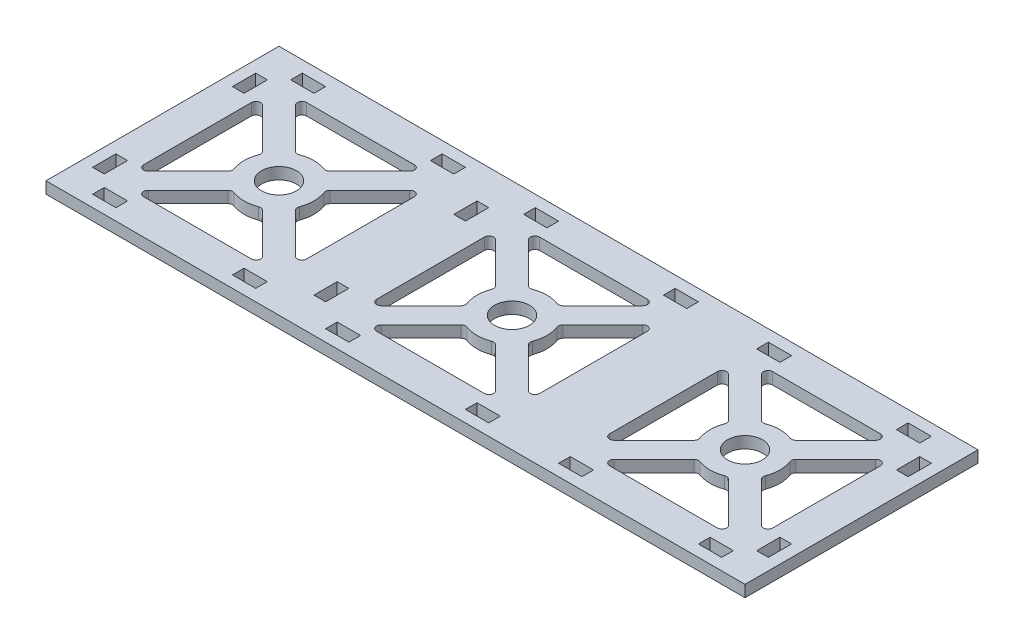
from build123d import *

# Parameters (mm, degrees)
SKETCH1_R           = 7.5
SKETCH1_W           = 10
SKETCH1_H           = 5
SKETCH1_W_2         = 5
SKETCH1_H_2         = 10
BOSS_EXTRUDE2_DEPTH = 5


with BuildPart() as part:
    # Sketch1 → Boss-Extrude2 (new body)
    with BuildSketch(Plane(origin=(0, 0, 0), x_dir=(1, 0, 0), z_dir=(0, 1, 0))):
        Polygon((-50, 50), (150, 50), (150, -50), (-50, -50), (-150, -50), (-150, 50), align=None)
        Circle(SKETCH1_R, mode=Mode.SUBTRACT)
        with Locations((100, 0)):
            Circle(SKETCH1_R, mode=Mode.SUBTRACT)
        with Locations((-100, 0)):
            Circle(SKETCH1_R, mode=Mode.SUBTRACT)
        with BuildLine():
            Line((-23.100505063, 35), (23.100505063, 35))
            ThreePointArc((23.100505063, 35), (24.948264128, 33.765366865), (24.514718626, 31.585786438))
            Line((24.514718626, 31.585786438), (7.418917244, 14.489985056))
            ThreePointArc((7.418917244, 14.489985056), (6.425915745, 13.949056578), (5.298267955, 14.033116428))
            ThreePointArc((5.298267955, 14.033116428), (0, 15), (-5.298267955, 14.033116428))
            ThreePointArc((-5.298267955, 14.033116428), (-6.425915745, 13.949056578), (-7.418917244, 14.489985056))
            Line((-7.418917244, 14.489985056), (-24.514718626, 31.585786438))
            ThreePointArc((-24.514718626, 31.585786438), (-24.948264128, 33.765366865), (-23.100505063, 35))
        make_face(mode=Mode.SUBTRACT)
        with BuildLine():
            Line((-35, 23.100505063), (-35, -23.100505063))
            ThreePointArc((-35, -23.100505063), (-33.765366865, -24.948264128), (-31.585786438, -24.514718626))
            Line((-31.585786438, -24.514718626), (-14.489985056, -7.418917244))
            ThreePointArc((-14.489985056, -7.418917244), (-13.949056578, -6.425915745), (-14.033116428, -5.298267955))
            ThreePointArc((-14.033116428, -5.298267955), (-15, 0), (-14.033116428, 5.298267955))
            ThreePointArc((-14.033116428, 5.298267955), (-13.949056578, 6.425915745), (-14.489985056, 7.418917244))
            Line((-14.489985056, 7.418917244), (-31.585786438, 24.514718626))
            ThreePointArc((-31.585786438, 24.514718626), (-33.765366865, 24.948264128), (-35, 23.100505063))
        make_face(mode=Mode.SUBTRACT)
        with BuildLine():
            Line((-23.100505063, -35), (23.100505063, -35))
            ThreePointArc((23.100505063, -35), (24.948264128, -33.765366865), (24.514718626, -31.585786438))
            Line((24.514718626, -31.585786438), (7.418917244, -14.489985056))
            ThreePointArc((7.418917244, -14.489985056), (6.425915745, -13.949056578), (5.298267955, -14.033116428))
            ThreePointArc((5.298267955, -14.033116428), (0, -15), (-5.298267955, -14.033116428))
            ThreePointArc((-5.298267955, -14.033116428), (-6.425915745, -13.949056578), (-7.418917244, -14.489985056))
            Line((-7.418917244, -14.489985056), (-24.514718626, -31.585786438))
            ThreePointArc((-24.514718626, -31.585786438), (-24.948264128, -33.765366865), (-23.100505063, -35))
        make_face(mode=Mode.SUBTRACT)
        with BuildLine():
            Line((35, 23.100505063), (35, -23.100505063))
            ThreePointArc((35, -23.100505063), (33.765366865, -24.948264128), (31.585786438, -24.514718626))
            Line((31.585786438, -24.514718626), (14.489985056, -7.418917244))
            ThreePointArc((14.489985056, -7.418917244), (13.949056578, -6.425915745), (14.033116428, -5.298267955))
            ThreePointArc((14.033116428, -5.298267955), (15, 0), (14.033116428, 5.298267955))
            ThreePointArc((14.033116428, 5.298267955), (13.949056578, 6.425915745), (14.489985056, 7.418917244))
            Line((14.489985056, 7.418917244), (31.585786438, 24.514718626))
            ThreePointArc((31.585786438, 24.514718626), (33.765366865, 24.948264128), (35, 23.100505063))
        make_face(mode=Mode.SUBTRACT)
        with BuildLine():
            Line((131.585786438, -24.514718626), (114.489985056, -7.418917244))
            ThreePointArc((114.489985056, -7.418917244), (113.949056578, -6.425915745), (114.033116428, -5.298267955))
            ThreePointArc((114.033116428, -5.298267955), (115, 0), (114.033116428, 5.298267955))
            ThreePointArc((114.033116428, 5.298267955), (113.949056578, 6.425915745), (114.489985056, 7.418917244))
            Line((114.489985056, 7.418917244), (131.585786438, 24.514718626))
            ThreePointArc((131.585786438, 24.514718626), (133.765366865, 24.948264128), (135, 23.100505063))
            Line((135, 23.100505063), (135, -23.100505063))
            ThreePointArc((135, -23.100505063), (133.765366865, -24.948264128), (131.585786438, -24.514718626))
        make_face(mode=Mode.SUBTRACT)
        with BuildLine():
            Line((124.514718626, -31.585786438), (107.418917244, -14.489985056))
            ThreePointArc((107.418917244, -14.489985056), (106.425915745, -13.949056578), (105.298267955, -14.033116428))
            ThreePointArc((105.298267955, -14.033116428), (100, -15), (94.701732045, -14.033116428))
            ThreePointArc((94.701732045, -14.033116428), (93.574084255, -13.949056578), (92.581082756, -14.489985056))
            Line((92.581082756, -14.489985056), (75.485281374, -31.585786438))
            ThreePointArc((75.485281374, -31.585786438), (75.051735872, -33.765366865), (76.899494937, -35))
            Line((76.899494937, -35), (123.100505063, -35))
            ThreePointArc((123.100505063, -35), (124.948264128, -33.765366865), (124.514718626, -31.585786438))
        make_face(mode=Mode.SUBTRACT)
        with BuildLine():
            Line((68.414213562, -24.514718626), (85.510014944, -7.418917244))
            ThreePointArc((85.510014944, -7.418917244), (86.050943422, -6.425915745), (85.966883572, -5.298267955))
            ThreePointArc((85.966883572, -5.298267955), (85, 0), (85.966883572, 5.298267955))
            ThreePointArc((85.966883572, 5.298267955), (86.050943422, 6.425915745), (85.510014944, 7.418917244))
            Line((85.510014944, 7.418917244), (68.414213562, 24.514718626))
            ThreePointArc((68.414213562, 24.514718626), (66.234633135, 24.948264128), (65, 23.100505063))
            Line((65, 23.100505063), (65, -23.100505063))
            ThreePointArc((65, -23.100505063), (66.234633135, -24.948264128), (68.414213562, -24.514718626))
        make_face(mode=Mode.SUBTRACT)
        with BuildLine():
            Line((75.485281374, 31.585786438), (92.581082756, 14.489985056))
            ThreePointArc((92.581082756, 14.489985056), (93.574084255, 13.949056578), (94.701732045, 14.033116428))
            ThreePointArc((94.701732045, 14.033116428), (100, 15), (105.298267955, 14.033116428))
            ThreePointArc((105.298267955, 14.033116428), (106.425915745, 13.949056578), (107.418917244, 14.489985056))
            Line((107.418917244, 14.489985056), (124.514718626, 31.585786438))
            ThreePointArc((124.514718626, 31.585786438), (124.948264128, 33.765366865), (123.100505063, 35))
            Line((123.100505063, 35), (76.899494937, 35))
            ThreePointArc((76.899494937, 35), (75.051735872, 33.765366865), (75.485281374, 31.585786438))
        make_face(mode=Mode.SUBTRACT)
        with BuildLine():
            Line((-68.414213562, -24.514718626), (-85.510014944, -7.418917244))
            ThreePointArc((-85.510014944, -7.418917244), (-86.050943422, -6.425915745), (-85.966883572, -5.298267955))
            ThreePointArc((-85.966883572, -5.298267955), (-85, 0), (-85.966883572, 5.298267955))
            ThreePointArc((-85.966883572, 5.298267955), (-86.050943422, 6.425915745), (-85.510014944, 7.418917244))
            Line((-85.510014944, 7.418917244), (-68.414213562, 24.514718626))
            ThreePointArc((-68.414213562, 24.514718626), (-66.234633135, 24.948264128), (-65, 23.100505063))
            Line((-65, 23.100505063), (-65, -23.100505063))
            ThreePointArc((-65, -23.100505063), (-66.234633135, -24.948264128), (-68.414213562, -24.514718626))
        make_face(mode=Mode.SUBTRACT)
        with BuildLine():
            Line((-75.485281374, -31.585786438), (-92.581082756, -14.489985056))
            ThreePointArc((-92.581082756, -14.489985056), (-93.574084255, -13.949056578), (-94.701732045, -14.033116428))
            ThreePointArc((-94.701732045, -14.033116428), (-100, -15), (-105.298267955, -14.033116428))
            ThreePointArc((-105.298267955, -14.033116428), (-106.425915745, -13.949056578), (-107.418917244, -14.489985056))
            Line((-107.418917244, -14.489985056), (-124.514718626, -31.585786438))
            ThreePointArc((-124.514718626, -31.585786438), (-124.948264128, -33.765366865), (-123.100505063, -35))
            Line((-123.100505063, -35), (-76.899494937, -35))
            ThreePointArc((-76.899494937, -35), (-75.051735872, -33.765366865), (-75.485281374, -31.585786438))
        make_face(mode=Mode.SUBTRACT)
        with BuildLine():
            Line((-131.585786438, -24.514718626), (-114.489985056, -7.418917244))
            ThreePointArc((-114.489985056, -7.418917244), (-113.949056578, -6.425915745), (-114.033116428, -5.298267955))
            ThreePointArc((-114.033116428, -5.298267955), (-115, 0), (-114.033116428, 5.298267955))
            ThreePointArc((-114.033116428, 5.298267955), (-113.949056578, 6.425915745), (-114.489985056, 7.418917244))
            Line((-114.489985056, 7.418917244), (-131.585786438, 24.514718626))
            ThreePointArc((-131.585786438, 24.514718626), (-133.765366865, 24.948264128), (-135, 23.100505063))
            Line((-135, 23.100505063), (-135, -23.100505063))
            ThreePointArc((-135, -23.100505063), (-133.765366865, -24.948264128), (-131.585786438, -24.514718626))
        make_face(mode=Mode.SUBTRACT)
        with BuildLine():
            Line((-124.514718626, 31.585786438), (-107.418917244, 14.489985056))
            ThreePointArc((-107.418917244, 14.489985056), (-106.425915745, 13.949056578), (-105.298267955, 14.033116428))
            ThreePointArc((-105.298267955, 14.033116428), (-100, 15), (-94.701732045, 14.033116428))
            ThreePointArc((-94.701732045, 14.033116428), (-93.574084255, 13.949056578), (-92.581082756, 14.489985056))
            Line((-92.581082756, 14.489985056), (-75.485281374, 31.585786438))
            ThreePointArc((-75.485281374, 31.585786438), (-75.051735872, 33.765366865), (-76.899494937, 35))
            Line((-76.899494937, 35), (-123.100505063, 35))
            ThreePointArc((-123.100505063, 35), (-124.948264128, 33.765366865), (-124.514718626, 31.585786438))
        make_face(mode=Mode.SUBTRACT)
        with Locations((-70, 42.5)):
            Rectangle(SKETCH1_W, SKETCH1_H, mode=Mode.SUBTRACT)
        with Locations((-130, 42.5)):
            Rectangle(SKETCH1_W, SKETCH1_H, mode=Mode.SUBTRACT)
        with Locations((-30, 42.5)):
            Rectangle(SKETCH1_W, SKETCH1_H, mode=Mode.SUBTRACT)
        with Locations((130, 42.5)):
            Rectangle(SKETCH1_W, SKETCH1_H, mode=Mode.SUBTRACT)
        with Locations((30, 42.5)):
            Rectangle(SKETCH1_W, SKETCH1_H, mode=Mode.SUBTRACT)
        with Locations((70, 42.5)):
            Rectangle(SKETCH1_W, SKETCH1_H, mode=Mode.SUBTRACT)
        with Locations((130, -42.5)):
            Rectangle(SKETCH1_W, SKETCH1_H, mode=Mode.SUBTRACT)
        with Locations((70, -42.5)):
            Rectangle(SKETCH1_W, SKETCH1_H, mode=Mode.SUBTRACT)
        with Locations((30, -42.5)):
            Rectangle(SKETCH1_W, SKETCH1_H, mode=Mode.SUBTRACT)
        with Locations((-130, -42.5)):
            Rectangle(SKETCH1_W, SKETCH1_H, mode=Mode.SUBTRACT)
        with Locations((-70, -42.5)):
            Rectangle(SKETCH1_W, SKETCH1_H, mode=Mode.SUBTRACT)
        with Locations((-30, -42.5)):
            Rectangle(SKETCH1_W, SKETCH1_H, mode=Mode.SUBTRACT)
        with Locations((-142.5, -30)):
            Rectangle(SKETCH1_W_2, SKETCH1_H_2, mode=Mode.SUBTRACT)
        with Locations((-142.5, 30)):
            Rectangle(SKETCH1_W_2, SKETCH1_H_2, mode=Mode.SUBTRACT)
        with Locations((142.5, -30)):
            Rectangle(SKETCH1_W_2, SKETCH1_H_2, mode=Mode.SUBTRACT)
        with Locations((142.5, 30)):
            Rectangle(SKETCH1_W_2, SKETCH1_H_2, mode=Mode.SUBTRACT)
        with Locations((-47.5, 30)):
            Rectangle(SKETCH1_W_2, SKETCH1_H_2, mode=Mode.SUBTRACT)
        with Locations((-47.5, -30)):
            Rectangle(SKETCH1_W_2, SKETCH1_H_2, mode=Mode.SUBTRACT)
    extrude(amount=BOSS_EXTRUDE2_DEPTH)


solid = part.part
